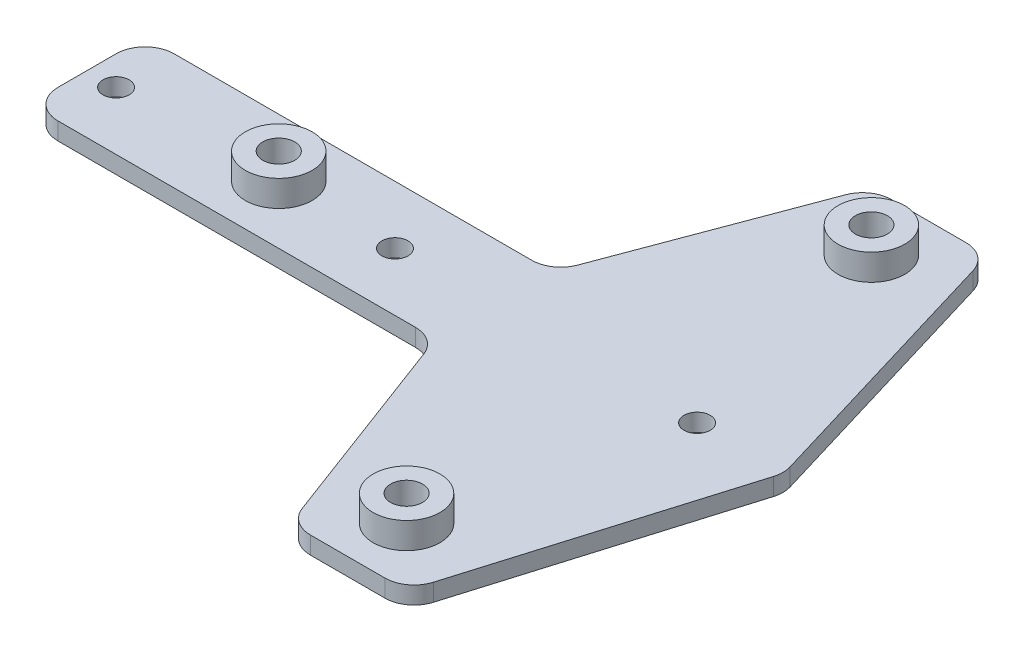
from build123d import *

# Parameters (mm, degrees)
BOSS_EXTRUDE1_DEPTH = 3
SKETCH2_R           = 2.75
CUT_EXTRUDE1_DEPTH  = 4
SKETCH3_R           = 5.75
SKETCH3_R_2         = 2.75
BOSS_EXTRUDE2_DEPTH = 4.5
SKETCH4_R           = 2.25
CUT_EXTRUDE2_DEPTH  = 4


with BuildPart() as part:
    # Sketch1 → Boss-Extrude1 (new body)
    with BuildSketch(Plane(origin=(0, 0, 0), x_dir=(1, 0, 0), z_dir=(0, 1, 0))):
        with BuildLine():
            Line((-55, 10), (6.534997659, 10))
            ThreePointArc((6.534997659, 10), (9.382971848, 10.890371912), (11.216643547, 13.244382792))
            Line((11.216643547, 13.244382792), (23.783356453, 46.755617208))
            ThreePointArc((23.783356453, 46.755617208), (25.617028152, 49.109628088), (28.465002341, 50))
            Line((28.465002341, 50), (41.279846746, 50))
            ThreePointArc((41.279846746, 50), (44.264499394, 49.011464641), (46.068978172, 46.436739428))
            Line((46.068978172, 46.436739428), (59.568978172, 1.436739428))
            ThreePointArc((59.568978172, 1.436739428), (59.779846746, 0), (59.568978172, -1.436739428))
            Line((59.568978172, -1.436739428), (46.068978172, -46.436739428))
            ThreePointArc((46.068978172, -46.436739428), (44.264499394, -49.011464641), (41.279846746, -50))
            Line((41.279846746, -50), (28.465002341, -50))
            ThreePointArc((28.465002341, -50), (25.617028152, -49.109628088), (23.783356453, -46.755617208))
            Line((23.783356453, -46.755617208), (11.216643547, -13.244382792))
            ThreePointArc((11.216643547, -13.244382792), (9.382971848, -10.890371912), (6.534997659, -10))
            Line((6.534997659, -10), (-55, -10))
            ThreePointArc((-55, -10), (-58.535533906, -8.535533906), (-60, -5))
            Line((-60, -5), (-60, 5))
            ThreePointArc((-60, 5), (-58.535533906, 8.535533906), (-55, 10))
        make_face()
    extrude(amount=BOSS_EXTRUDE1_DEPTH)

    # Sketch2 → Cut-Extrude1 (cut, through all)
    with BuildSketch(Plane(origin=(0, 3, 0), x_dir=(1, 0, 0), z_dir=(0, 1, 0))):
        with Locations((-27, 0)):
            Circle(SKETCH2_R)
        with Locations((35, 40)):
            Circle(SKETCH2_R)
        with Locations((35, -40)):
            Circle(SKETCH2_R)
    extrude(amount=-CUT_EXTRUDE1_DEPTH, mode=Mode.SUBTRACT)

    # Sketch3 → Boss-Extrude2 (add)
    with BuildSketch(Plane(origin=(0, 3, 0), x_dir=(1, 0, 0), z_dir=(0, 1, 0))):
        with Locations((-27, 0)):
            Circle(SKETCH3_R)
        with Locations((-27, 0)):
            Circle(SKETCH3_R_2, mode=Mode.SUBTRACT)
        with Locations((35, 40)):
            Circle(SKETCH3_R)
        with Locations((35, 40)):
            Circle(SKETCH3_R_2, mode=Mode.SUBTRACT)
        with Locations((35, -40)):
            Circle(SKETCH3_R)
        with Locations((35, -40)):
            Circle(SKETCH3_R_2, mode=Mode.SUBTRACT)
    extrude(amount=BOSS_EXTRUDE2_DEPTH)

    # Sketch4 → Cut-Extrude2 (cut, through all)
    with BuildSketch(Plane(origin=(0, 3, 0), x_dir=(1, 0, 0), z_dir=(0, 1, 0))):
        with Locations((-55, 0)):
            Circle(SKETCH4_R)
        with Locations((45, 0)):
            Circle(SKETCH4_R)
        with Locations((-7, 0)):
            Circle(SKETCH4_R)
    extrude(amount=-CUT_EXTRUDE2_DEPTH, mode=Mode.SUBTRACT)


solid = part.part
